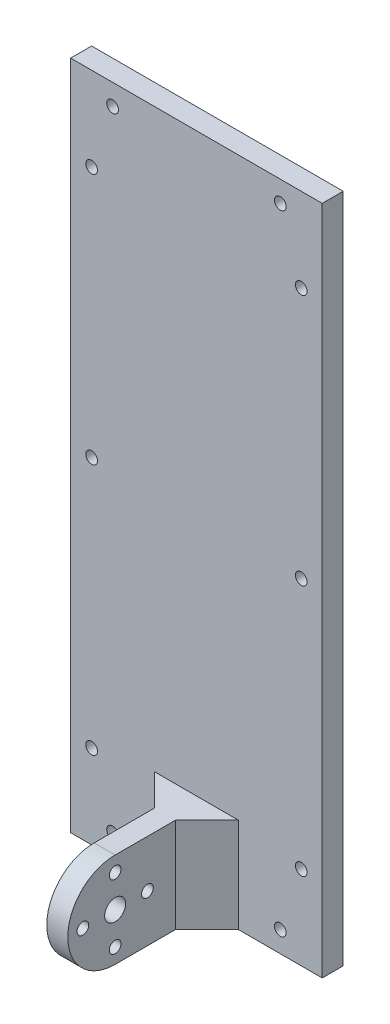
from build123d import *

# Parameters (mm, degrees)
SKETCH1_W           = 76.2
SKETCH1_H           = 203.2
BOSS_EXTRUDE1_DEPTH = 6.35
SKETCH2_W           = 6.35
SKETCH2_H           = 28.702
BOSS_EXTRUDE2_DEPTH = 44.45
SKETCH3_R           = 3.175
CUT_EXTRUDE1_DEPTH  = 6.35
SKETCH4_R           = 1.778
CUT_EXTRUDE2_DEPTH  = 6.35
CIRPATTERN1_COUNT   = 4
CUT_EXTRUDE3_DEPTH  = 6.35
SKETCH6_R           = 1.778
CUT_EXTRUDE4_DEPTH  = 6.35
BOSS_EXTRUDE3_DEPTH = 28.702


with BuildPart() as part:
    # Sketch1 → Boss-Extrude1 (new body)
    with BuildSketch(Plane.XY):
        with Locations((38.1, 101.6)):
            Rectangle(SKETCH1_W, SKETCH1_H)
    extrude(amount=BOSS_EXTRUDE1_DEPTH)

    # Sketch2 → Boss-Extrude2 (add)
    with BuildSketch(Plane.XY.offset(6.35)):
        with Locations((38.1, 14.351)):
            Rectangle(SKETCH2_W, SKETCH2_H)
    extrude(amount=BOSS_EXTRUDE2_DEPTH)

    # Sketch3 → Cut-Extrude1 (cut)
    with BuildSketch(Plane(origin=(41.275, 0, 0), x_dir=(0, 0, -1), z_dir=(1, 0, 0))):
        with Locations((-34.154615714, 14.351)):
            Circle(SKETCH3_R)
    extrude(amount=-CUT_EXTRUDE1_DEPTH, mode=Mode.SUBTRACT)

    # Sketch4 → Cut-Extrude2 (cut)
    with BuildSketch(Plane(origin=(41.275, 0, 0), x_dir=(0, 0, -1), z_dir=(1, 0, 0))):
        with Locations((-43.933615714, 14.351)):
            Circle(SKETCH4_R)
    cut_extrude2 = extrude(amount=-CUT_EXTRUDE2_DEPTH, mode=Mode.SUBTRACT)

    # CirPattern1: Cut-Extrude2 ×4 about axis
    cirpattern1_axis = Axis((0, 14.351, 34.154615714), (1, 0, 0))
    for i in range(1, CIRPATTERN1_COUNT):
        add(cut_extrude2.rotate(cirpattern1_axis, i * 360 / CIRPATTERN1_COUNT), mode=Mode.SUBTRACT)

    # Sketch5 → Cut-Extrude3 (cut)
    with BuildSketch(Plane(origin=(41.275, 0, 0), x_dir=(0, 0, -1), z_dir=(1, 0, 0))):
        with BuildLine():
            ThreePointArc((-34.154615714, 0), (-48.505615714, 14.351), (-34.154615714, 28.702))
            Line((-34.154615714, 28.702), (-50.8, 28.702))
            Line((-50.8, 28.702), (-50.8, 0))
            Line((-50.8, 0), (-34.154615714, 0))
        make_face()
    extrude(amount=-CUT_EXTRUDE3_DEPTH, mode=Mode.SUBTRACT)

    # Sketch6 → Cut-Extrude4 (cut)
    with BuildSketch(Plane(origin=(0, 0, 0), x_dir=(-1, 0, 0), z_dir=(0, 0, -1))):
        with Locations((-63.5, 6.35)):
            Circle(SKETCH6_R)
        with Locations((-12.7, 6.35)):
            Circle(SKETCH6_R)
        with Locations((-6.35, 177.8)):
            Circle(SKETCH6_R)
        with Locations((-6.35, 25.4)):
            Circle(SKETCH6_R)
        with Locations((-69.85, 25.4)):
            Circle(SKETCH6_R)
        with Locations((-69.85, 177.8)):
            Circle(SKETCH6_R)
        with Locations((-63.5, 196.85)):
            Circle(SKETCH6_R)
        with Locations((-12.7, 196.85)):
            Circle(SKETCH6_R)
        with Locations((-6.35, 101.6)):
            Circle(SKETCH6_R)
        with Locations((-69.85, 101.6)):
            Circle(SKETCH6_R)
    extrude(amount=-CUT_EXTRUDE4_DEPTH, mode=Mode.SUBTRACT)

    # Sketch8 → Boss-Extrude3 (add)
    with BuildSketch(Plane.XZ):
        Polygon((41.275, 6.35), (41.275, 15.875), (50.8, 6.35), align=None)
        Polygon((34.925, 6.35), (34.925, 15.875), (25.4, 6.35), align=None)
    extrude(amount=-BOSS_EXTRUDE3_DEPTH)


solid = part.part
